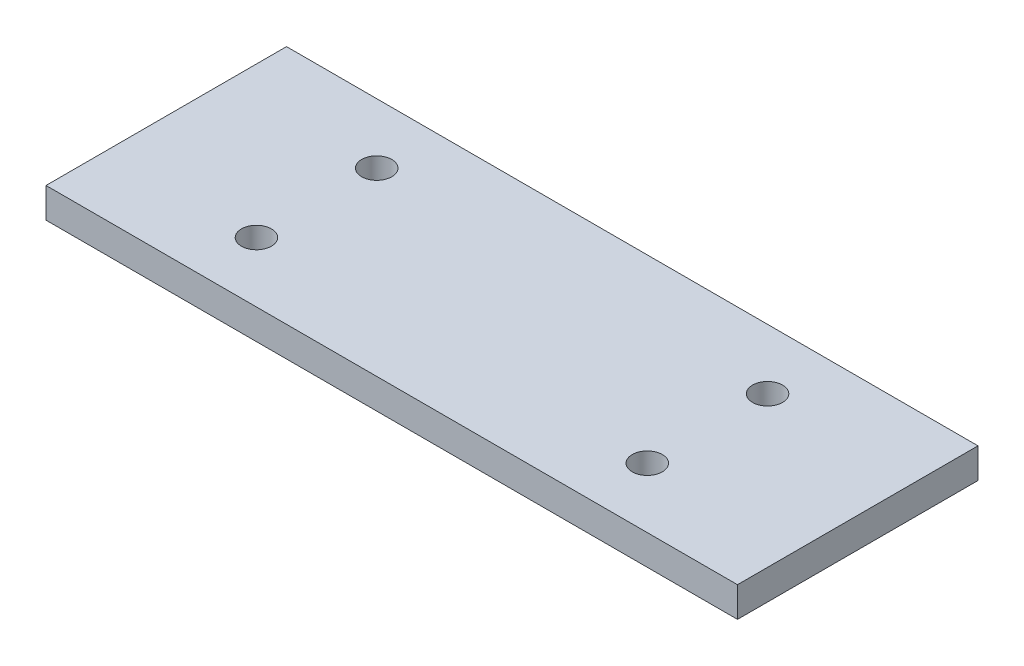
from build123d import *

# Parameters (mm, degrees)
SKETCH2_W           = 115
SKETCH2_H           = 40
SKETCH2_R           = 2.5
BOSS_EXTRUDE1_DEPTH = 5


with BuildPart() as part:
    # Sketch2 → Boss-Extrude1 (new body)
    with BuildSketch(Plane(origin=(0, 0, 0), x_dir=(1, 0, 0), z_dir=(0, 1, 0))):
        with Locations((57.5, 20)):
            Rectangle(SKETCH2_W, SKETCH2_H)
        with Locations((25, 30)):
            Circle(SKETCH2_R, mode=Mode.SUBTRACT)
        with Locations((25, 10)):
            Circle(SKETCH2_R, mode=Mode.SUBTRACT)
        with Locations((90, 10)):
            Circle(SKETCH2_R, mode=Mode.SUBTRACT)
        with Locations((90, 30)):
            Circle(SKETCH2_R, mode=Mode.SUBTRACT)
    extrude(amount=BOSS_EXTRUDE1_DEPTH)


solid = part.part
